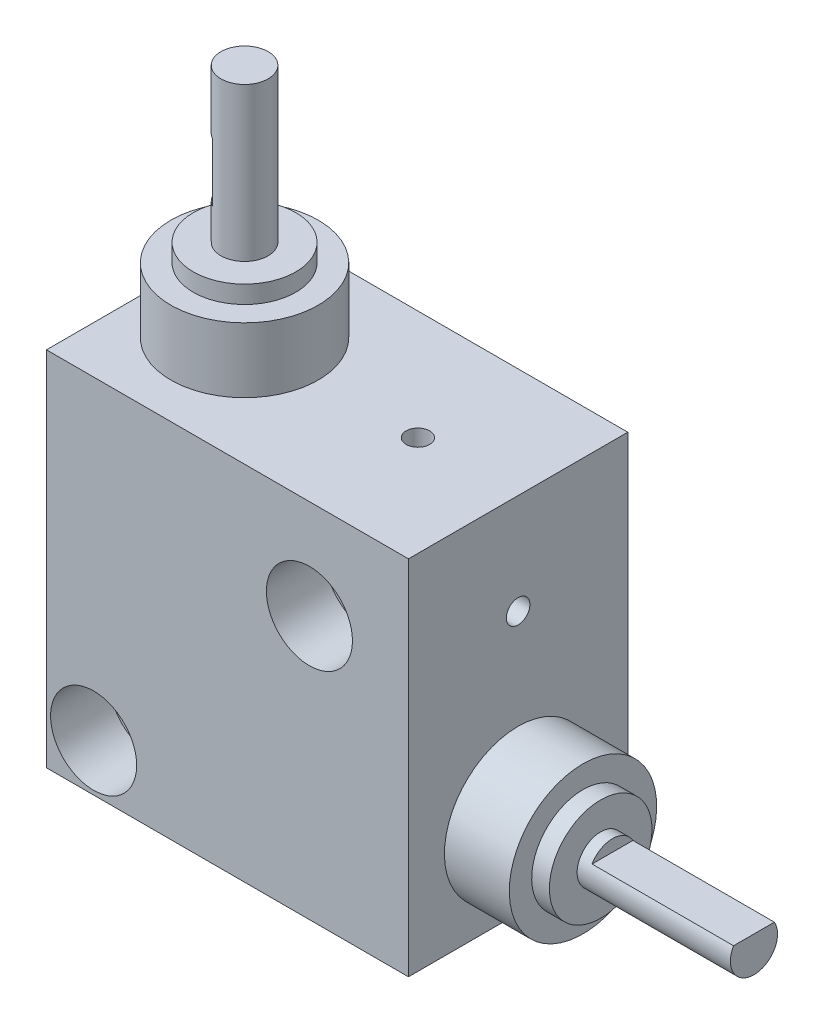
from build123d import *

# Parameters (mm, degrees)
ESQUISSE1_W             = 30.7
ESQUISSE1_H             = 30.7
BOSS_EXTRU_1_DEPTH      = 9.3
ESQUISSE2_R             = 2
ENL_V_MAT_EXTRU_1_DEPTH = 19.6
ESQUISSE3_R             = 3.65
ENL_V_MAT_EXTRU_2_DEPTH = 5
ESQUISSE4_R             = 3.65
ENL_V_MAT_EXTRU_3_DEPTH = 5
ESQUISSE9_W             = 1
ESQUISSE9_H             = 4
ENL_V_MAT_EXTRU_4_DEPTH = 5
ESQUISSE10_W            = 4
ESQUISSE10_H            = 1
ENL_V_MAT_EXTRU_5_DEPTH = 12
ESQUISSE11_R            = 1
ENL_V_MAT_EXTRU_6_DEPTH = 5
ESQUISSE13_R            = 1
ENL_V_MAT_EXTRU_7_DEPTH = 5


with BuildPart() as part:
    # Esquisse1 → Boss.-Extru.1 (new body, symmetric)
    with BuildSketch(Plane.XY):
        with Locations((15.35, 15.35)):
            Rectangle(ESQUISSE1_W, ESQUISSE1_H)
    extrude(amount=BOSS_EXTRU_1_DEPTH, both=True)

    # Esquisse2 → Enlèv. mat.-Extru.1 (cut, through all)
    with BuildSketch(Plane.XY.offset(9.3)):
        with Locations((4, 4)):
            Circle(ESQUISSE2_R)
        with Locations((22.3, 22.3)):
            Circle(ESQUISSE2_R)
    extrude(amount=-ENL_V_MAT_EXTRU_1_DEPTH, mode=Mode.SUBTRACT)

    # Esquisse3 → Enlèv. mat.-Extru.2 (cut)
    with BuildSketch(Plane.XY.offset(9.3)):
        with Locations((4, 4)):
            Circle(ESQUISSE3_R)
        with Locations((22.3, 22.3)):
            Circle(ESQUISSE3_R)
    extrude(amount=-ENL_V_MAT_EXTRU_2_DEPTH, mode=Mode.SUBTRACT)

    # Esquisse4 → Enlèv. mat.-Extru.3 (cut)
    with BuildSketch(Plane(origin=(0, 0, -9.3), x_dir=(-1, 0, 0), z_dir=(0, 0, -1))):
        with Locations((-4, 4)):
            Circle(ESQUISSE4_R)
        with Locations((-22.3, 22.3)):
            Circle(ESQUISSE4_R)
    extrude(amount=-ENL_V_MAT_EXTRU_3_DEPTH, mode=Mode.SUBTRACT)

    # Esquisse6 → Révolution1 (revolve)
    with BuildSketch(Plane.XY):
        Polygon((30.7, 13.75), (36.2, 13.75), (36.2, 11.85), (37.7, 11.85), (37.7, 9.5), (50.7, 9.5), (50.7, 7.5), (30.7, 7.5), align=None)
    revolve(axis=Axis((50.7, 7.5, 0), (-1, 0, 0)))

    # Esquisse10 → Enlèv. mat.-Extru.5 (cut)
    with BuildSketch(Plane(origin=(50.7, 0, 0), x_dir=(0, 0, -1), z_dir=(1, 0, 0))):
        with Locations((0, 9)):
            Rectangle(ESQUISSE10_W, ESQUISSE10_H)
    extrude(amount=-ENL_V_MAT_EXTRU_5_DEPTH, mode=Mode.SUBTRACT)

    # Esquisse11 → Enlèv. mat.-Extru.6 (cut)
    with BuildSketch(Plane(origin=(30.7, 0, 0), x_dir=(0, 0, -1), z_dir=(1, 0, 0))):
        with Locations((0, 22.2)):
            Circle(ESQUISSE11_R)
    extrude(amount=-ENL_V_MAT_EXTRU_6_DEPTH, mode=Mode.SUBTRACT)

    # Esquisse13 → Enlèv. mat.-Extru.7 (cut)
    with BuildSketch(Plane(origin=(0, 30.7, 0), x_dir=(1, 0, 0), z_dir=(0, 1, 0))):
        with Locations((22.2, 0)):
            Circle(ESQUISSE13_R)
    extrude(amount=-ENL_V_MAT_EXTRU_7_DEPTH, mode=Mode.SUBTRACT)


with BuildPart() as body_2:
    # Esquisse8 → Révolution2 (revolve)
    with BuildSketch(Plane.XY):
        Polygon((1.25, 30.7), (1.25, 36.2), (3.15, 36.2), (3.15, 37.7), (5.5, 37.7), (5.5, 50.7), (7.5, 50.7), (7.5, 30.7), align=None)
    revolve(axis=Axis((7.5, 50.7, 0), (0, -1, 0)))

    # Esquisse9 → Enlèv. mat.-Extru.4 (cut)
    with BuildSketch(Plane(origin=(0, 45.7, 0), x_dir=(1, 0, 0), z_dir=(0, 1, 0))):
        with Locations((6, 0)):
            Rectangle(ESQUISSE9_W, ESQUISSE9_H)
    extrude(amount=-ENL_V_MAT_EXTRU_4_DEPTH, mode=Mode.SUBTRACT)


solid = Compound([part.part, body_2.part])
